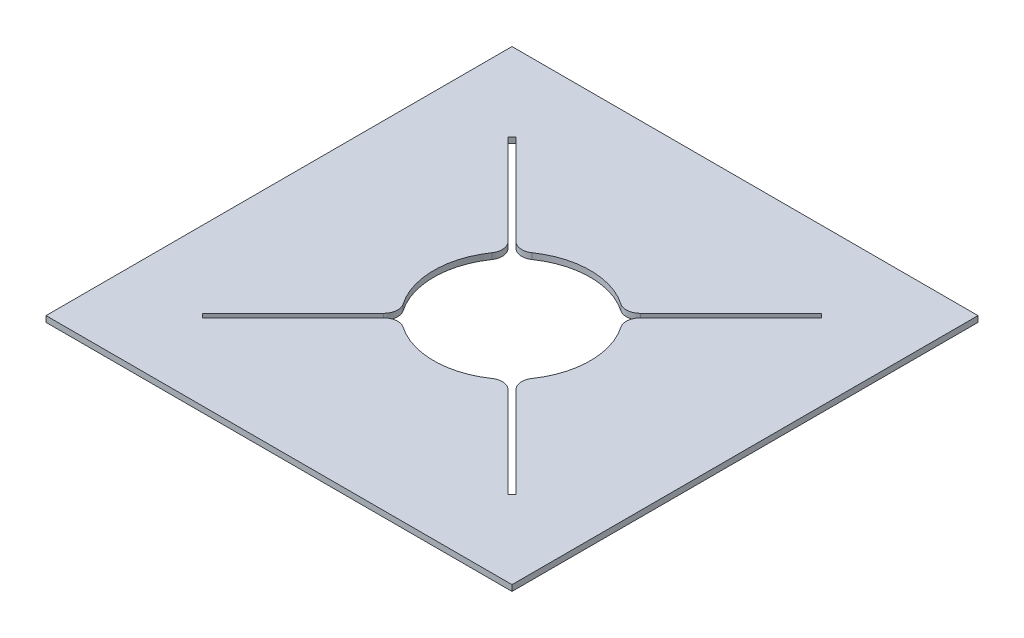
from build123d import *

# Parameters (mm, degrees)
SKETCH1_W           = 500
SKETCH1_H           = 500
BOSS_EXTRUDE1_DEPTH = 6.35
SKETCH2_R           = 84
CUT_EXTRUDE1_DEPTH  = 6.35
CUT_EXTRUDE3_DEPTH  = 6.35
FILLET1_R           = 15


with BuildPart() as part:
    # Sketch1 → Boss-Extrude1 (new body)
    with BuildSketch(Plane(origin=(0, 0, 0), x_dir=(1, 0, 0), z_dir=(0, 1, 0))):
        with Locations((48.037604912, -85.456276451)):
            Rectangle(SKETCH1_W, SKETCH1_H)
    extrude(amount=BOSS_EXTRUDE1_DEPTH)

    # Sketch2 → Cut-Extrude1 (cut)
    with BuildSketch(Plane(origin=(0, 6.35, 0), x_dir=(1, 0, 0), z_dir=(0, 1, 0))):
        with Locations((48.037604912, -85.456276451)):
            Circle(SKETCH2_R)
    extrude(amount=-CUT_EXTRUDE1_DEPTH, mode=Mode.SUBTRACT)

    # Sketch3 → Cut-Extrude3 (cut)
    with BuildSketch(Plane(origin=(0, 6.35, 0), x_dir=(1, 0, 0), z_dir=(0, 1, 0))):
        Polygon((216.329018834, 78.592496784), (103.191933845, -34.544588206), (98.949293158, -30.301947519), (212.086378147, 82.835137471), align=None)
        Polygon((-120.25380901, 78.592496784), (-116.011168323, 82.835137471), (-2.874083333, -30.301947519), (-7.11672402, -34.544588206), align=None)
        Polygon((212.086378147, -253.747690374), (98.949293158, -140.610605384), (103.191933845, -136.367964697), (216.329018835, -249.505049687), align=None)
        Polygon((-120.25380901, -249.505049687), (-7.11672402, -136.367964697), (-2.874083333, -140.610605384), (-116.011168323, -253.747690374), align=None)
    extrude(amount=-CUT_EXTRUDE3_DEPTH, mode=Mode.SUBTRACT)

    # Fillet1
    fillet1_edges = [part.edges().sort_by_distance(p)[0] for p in [
        (105.275361381, 3.175, 23.975879296),
        (109.518002068, 3.175, 28.218519983),
        (109.518002068, 3.175, 142.69403292),
        (105.275361381, 3.175, 146.936673607),
        (-13.442792244, 3.175, 142.69403292),
        (-9.200151557, 3.175, 146.936673607),
        (-13.442792244, 3.175, 28.218519983),
        (-9.200151557, 3.175, 23.975879296),
    ]]
    fillet(fillet1_edges, radius=FILLET1_R)


solid = part.part
